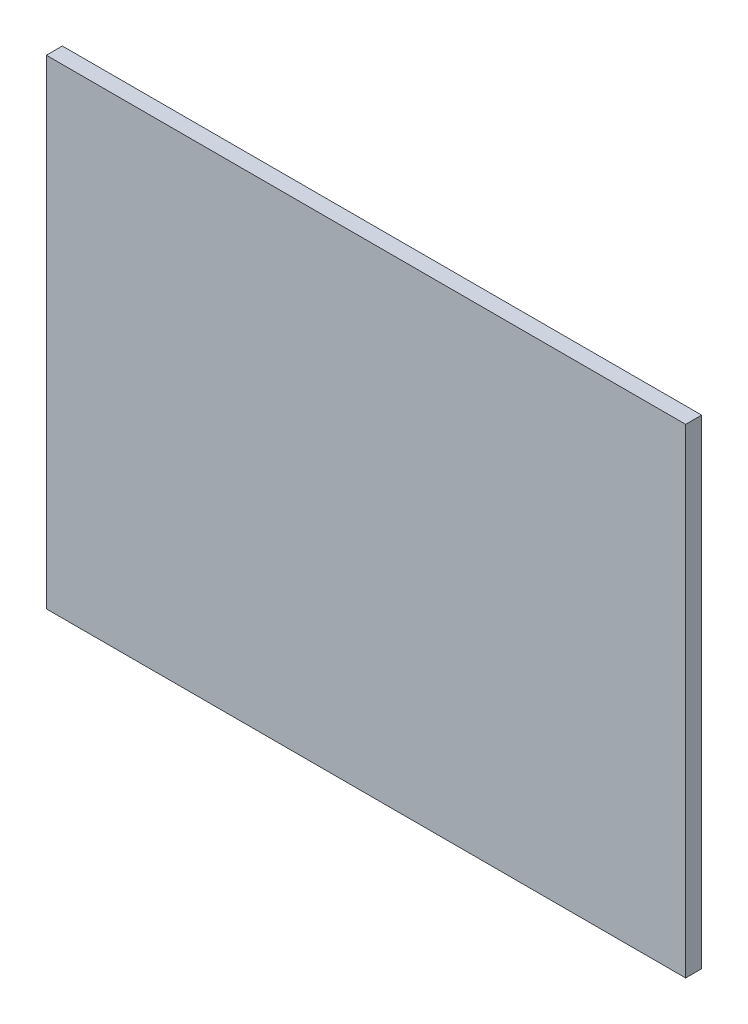
from build123d import *

# Parameters (mm, degrees)
SKIZZE1_W                       = 80
SKIZZE1_H                       = 60
AUFSATZ_LINEAR_AUSTRAGEN1_DEPTH = 2


with BuildPart() as part:
    # Skizze1 → Aufsatz-Linear austragen1 (new body)
    with BuildSketch(Plane.XY):
        Rectangle(SKIZZE1_W, SKIZZE1_H)
    extrude(amount=AUFSATZ_LINEAR_AUSTRAGEN1_DEPTH)


solid = part.part
